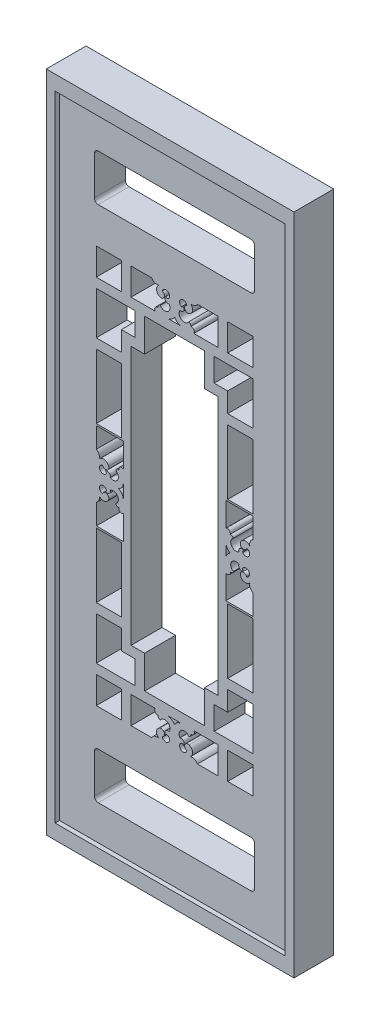
from build123d import *

# Parameters (mm, degrees)
SKETCH1_W            = 595
SKETCH1_H            = 1640
BOSS_EXTRUDE1_DEPTH  = 180
SKETCH_6_W           = 595
SKETCH_6_H           = 1640
CUT_EXTRUDE_2_DEPTH  = 100
CUT_EXTRUDE_3_DEPTH  = 100
SKETCH2_W            = 65
SKETCH2_H            = 70
SKETCH2_H_2          = 167
CUT_EXTRUDE_5_DEPTH  = 1747.432077122
CUT_EXTRUDE_8_DEPTH  = 1747.432077122
SCALE_1_SCALE        = 0.87394958
EXTRUDE_1_DEPTH      = 10
EXTRUDE_1_DEPTH_BACK = 79.92
SKETCH_8_W           = 560
SKETCH_8_H           = 1500
SKETCH_8_W_2         = 520
SKETCH_8_H_2         = 1433.277310924


with BuildPart() as part:
    # Sketch1 → Boss-Extrude1 (new body)
    with BuildSketch(Plane.XY):
        with Locations((297.5, 820)):
            Rectangle(SKETCH1_W, SKETCH1_H)
    extrude(amount=BOSS_EXTRUDE1_DEPTH)

    # 草图6 → 切除-拉伸2 (cut)
    with BuildSketch(Plane.XY.offset(180)):
        with Locations((297.5, 820)):
            Rectangle(SKETCH_6_W, SKETCH_6_H)
    extrude(amount=-CUT_EXTRUDE_2_DEPTH, mode=Mode.SUBTRACT)

    # 草图1 → 切除-拉伸3 (cut)
    with BuildSketch(Plane(origin=(0, 0, 0), x_dir=(-1, 0, 0), z_dir=(0, 0, -1))):
        with BuildLine():
            ThreePointArc((-339.478697135, 363.442307012), (-347.464207716, 366.462464977), (-347.449072001, 375))
            Line((-347.449072001, 375), (-410, 375))
            Line((-410, 375), (-410, 305))
            Line((-410, 305), (-356.673331708, 305))
            ThreePointArc((-356.673331708, 305), (-348.94904931, 312.012889726), (-338.529552639, 312.541330816))
            ThreePointArc((-338.529552639, 312.541330816), (-344.046220029, 325.924483031), (-334.768909443, 337.036363636))
            ThreePointArc((-334.768909443, 337.036363636), (-323.949287324, 331.726907665), (-329.315168468, 320.935157804))
            ThreePointArc((-329.315168468, 320.935157804), (-314.478603669, 315.069270244), (-315.214046212, 331.006378394))
            ThreePointArc((-315.214046212, 331.006378394), (-318.365986632, 330.765395418), (-320.358708006, 328.311447022))
            ThreePointArc((-320.358708006, 328.311447022), (-320.882047686, 338.069212343), (-311.577227356, 341.053870966))
            ThreePointArc((-311.577227356, 341.053870966), (-311.192434776, 341.798442865), (-310.72696898, 342.495432272))
            ThreePointArc((-310.72696898, 342.495432272), (-316.343126273, 360.498534643), (-334.477239272, 355.321000146))
            ThreePointArc((-334.477239272, 355.321000146), (-338.751843962, 358.289222889), (-339.478697135, 363.442307012))
        make_face()
        with BuildLine():
            Line((-279.5, 375), (-315.5, 375))
            ThreePointArc((-315.5, 375), (-304.873925683, 371.412833197), (-297.5, 362.9626))
            ThreePointArc((-297.5, 362.9626), (-290.126074317, 371.412833197), (-279.5, 375))
        make_face()
        with BuildLine():
            Line((-185, 375), (-247.550927999, 375))
            ThreePointArc((-247.550927999, 375), (-247.535792284, 366.462464977), (-255.521302865, 363.442307012))
            ThreePointArc((-255.521302865, 363.442307012), (-256.248156038, 358.289222889), (-260.522760728, 355.321000146))
            ThreePointArc((-260.522760728, 355.321000146), (-278.656873727, 360.498534643), (-284.27303102, 342.495432272))
            ThreePointArc((-284.27303102, 342.495432272), (-283.807565224, 341.798442865), (-283.422772644, 341.053870966))
            ThreePointArc((-283.422772644, 341.053870966), (-274.117952314, 338.069212343), (-274.641291994, 328.311447022))
            ThreePointArc((-274.641291994, 328.311447022), (-276.634013368, 330.765395418), (-279.785953788, 331.006378394))
            ThreePointArc((-279.785953788, 331.006378394), (-280.521396331, 315.069270244), (-265.684831532, 320.935157804))
            ThreePointArc((-265.684831532, 320.935157804), (-271.050712676, 331.726907665), (-260.231090557, 337.036363636))
            ThreePointArc((-260.231090557, 337.036363636), (-250.953779971, 325.924483031), (-256.470447361, 312.541330816))
            ThreePointArc((-256.470447361, 312.541330816), (-246.05095069, 312.012889726), (-238.326668292, 305))
            Line((-238.326668292, 305), (-185, 305))
            Line((-185, 305), (-185, 375))
        make_face()
    cut_extrude_3 = extrude(amount=-CUT_EXTRUDE_3_DEPTH, mode=Mode.SUBTRACT)

    # Sketch2 → 切除-拉伸5 (cut, through all)
    with BuildSketch(Plane(origin=(0, 0, 0), x_dir=(-1, 0, 0), z_dir=(0, 0, -1))):
        with Locations((-467.5, 1300)):
            Rectangle(SKETCH2_W, SKETCH2_H)
        Polygon((-400, 1240), (-500, 1240), (-500, 1129), (-435, 1129), (-435, 1180), (-400, 1180), align=None)
        with Locations((-467.5, 1020.5)):
            Rectangle(SKETCH2_W, SKETCH2_H_2)
        Polygon((-220, 1240), (-375, 1240), (-375, 1155), (-410, 1155), (-410, 485), (-375, 485), (-375, 400), (-220, 400), (-220, 485), (-185, 485), (-185, 1155), (-220, 1155), align=None)
        with Locations((-127.5, 1300)):
            Rectangle(SKETCH2_W, SKETCH2_H)
        Polygon((-95, 1240), (-195, 1240), (-195, 1180), (-160, 1180), (-160, 1129), (-95, 1129), align=None)
        with Locations((-467.5, 619.5)):
            Rectangle(SKETCH2_W, SKETCH2_H_2)
        with Locations((-127.5, 1020.5)):
            Rectangle(SKETCH2_W, SKETCH2_H_2)
        Polygon((-435, 511), (-500, 511), (-500, 400), (-400, 400), (-400, 460), (-435, 460), align=None)
        Polygon((-195, 460), (-195, 400), (-95, 400), (-95, 511), (-160, 511), (-160, 460), align=None)
        with Locations((-467.5, 340)):
            Rectangle(SKETCH2_W, SKETCH2_H)
        with Locations((-127.5, 619.5)):
            Rectangle(SKETCH2_W, SKETCH2_H_2)
        with Locations((-127.5, 340)):
            Rectangle(SKETCH2_W, SKETCH2_H)
        with BuildLine():
            Line((-100, 210), (-495, 210))
            ThreePointArc((-495, 210), (-502.071067812, 207.071067812), (-505, 200))
            Line((-505, 200), (-505, 100))
            ThreePointArc((-505, 100), (-502.071067812, 92.928932188), (-495, 90))
            Line((-495, 90), (-100, 90))
            ThreePointArc((-100, 90), (-92.928932188, 92.928932188), (-90, 100))
            Line((-90, 100), (-90, 200))
            ThreePointArc((-90, 200), (-92.928932188, 207.071067812), (-100, 210))
        make_face()
        with BuildLine():
            Line((-100, 1550), (-495, 1550))
            ThreePointArc((-495, 1550), (-502.071067812, 1547.071067812), (-505, 1540))
            Line((-505, 1540), (-505, 1440))
            ThreePointArc((-505, 1440), (-502.071067812, 1432.928932188), (-495, 1430))
            Line((-495, 1430), (-100, 1430))
            ThreePointArc((-100, 1430), (-92.928932188, 1432.928932188), (-90, 1440))
            Line((-90, 1440), (-90, 1540))
            ThreePointArc((-90, 1540), (-92.928932188, 1547.071067812), (-100, 1550))
        make_face()
    extrude(amount=-CUT_EXTRUDE_5_DEPTH, mode=Mode.SUBTRACT)

    # 镜向1: 切除-拉伸3 across plane
    add(cut_extrude_3.mirror(Plane.ZX.offset(820)), mode=Mode.SUBTRACT)

    # 草图1<5> → 切除-拉伸8 (cut, through all)
    with BuildSketch(Plane(origin=(0, 0, 0), x_dir=(-1, 0, 0), z_dir=(0, 0, -1))):
        with BuildLine():
            Line((-500, 760.826668292), (-500, 707.5))
            Line((-500, 707.5), (-430, 707.5))
            Line((-430, 707.5), (-430, 770.050927999))
            ThreePointArc((-430, 770.050927999), (-438.537535023, 770.035792284), (-441.557692988, 778.021302865))
            ThreePointArc((-441.557692988, 778.021302865), (-446.710777111, 778.748156038), (-449.678999854, 783.022760728))
            ThreePointArc((-449.678999854, 783.022760728), (-444.501465357, 801.156873727), (-462.504567728, 806.77303102))
            ThreePointArc((-462.504567728, 806.77303102), (-463.201557135, 806.307565224), (-463.946129034, 805.922772644))
            ThreePointArc((-463.946129034, 805.922772644), (-466.930787657, 796.617952314), (-476.688552978, 797.141291994))
            ThreePointArc((-476.688552978, 797.141291994), (-474.234604582, 799.134013368), (-473.993621606, 802.285953788))
            ThreePointArc((-473.993621606, 802.285953788), (-489.930729756, 803.021396331), (-484.064842196, 788.184831532))
            ThreePointArc((-484.064842196, 788.184831532), (-473.273092335, 793.550712676), (-467.963636364, 782.731090557))
            ThreePointArc((-467.963636364, 782.731090557), (-479.075516969, 773.453779971), (-492.458669184, 778.970447361))
            ThreePointArc((-492.458669184, 778.970447361), (-492.987110274, 768.55095069), (-500, 760.826668292))
        make_face()
        with BuildLine():
            ThreePointArc((-442.0374, 820), (-433.587166803, 812.626074317), (-430, 802))
            Line((-430, 802), (-430, 838))
            ThreePointArc((-430, 838), (-433.587166803, 827.373925683), (-442.0374, 820))
        make_face()
        with BuildLine():
            Line((-430, 869.949072001), (-430, 932.5))
            Line((-430, 932.5), (-500, 932.5))
            Line((-500, 932.5), (-500, 879.173331708))
            ThreePointArc((-500, 879.173331708), (-492.987110274, 871.44904931), (-492.458669184, 861.029552639))
            ThreePointArc((-492.458669184, 861.029552639), (-479.075516969, 866.546220029), (-467.963636364, 857.268909443))
            ThreePointArc((-467.963636364, 857.268909443), (-473.273092335, 846.449287324), (-484.064842196, 851.815168468))
            ThreePointArc((-484.064842196, 851.815168468), (-489.930729756, 836.978603669), (-473.993621606, 837.714046212))
            ThreePointArc((-473.993621606, 837.714046212), (-474.234604582, 840.865986631), (-476.688552978, 842.858708006))
            ThreePointArc((-476.688552978, 842.858708006), (-466.930787657, 843.382047686), (-463.946129034, 834.077227356))
            ThreePointArc((-463.946129034, 834.077227356), (-463.201557135, 833.692434776), (-462.504567728, 833.22696898))
            ThreePointArc((-462.504567728, 833.22696898), (-444.501465357, 838.843126273), (-449.678999854, 856.977239272))
            ThreePointArc((-449.678999854, 856.977239272), (-446.710777111, 861.251843962), (-441.557692988, 861.978697135))
            ThreePointArc((-441.557692988, 861.978697135), (-438.537535023, 869.964207716), (-430, 869.949072001))
        make_face()
    cut_extrude_8 = extrude(amount=-CUT_EXTRUDE_8_DEPTH, mode=Mode.SUBTRACT)

    # 镜向3: 切除-拉伸8 across plane
    add(cut_extrude_8.mirror(Plane.ZY.offset(-297.5)), mode=Mode.SUBTRACT)


with BuildPart() as part_1:
    # 缩放比例1: scaled about (297.5, 820, 40)
    add(part.part.scale(SCALE_1_SCALE).moved(Location((37.5, 103.361344538, 5.042016807))))

    # 草图8 → 凸台-拉伸1 (add, two sides: drawn at the far end of the back side and taken through both)
    with BuildSketch(Plane.XY.offset(74.957983193).offset(-EXTRUDE_1_DEPTH_BACK)):
        with Locations((297.5, 820.001344538)):
            Rectangle(SKETCH_8_W, SKETCH_8_H)
        with Locations((297.5, 820)):
            Rectangle(SKETCH_8_W_2, SKETCH_8_H_2, mode=Mode.SUBTRACT)
    extrude(amount=EXTRUDE_1_DEPTH + EXTRUDE_1_DEPTH_BACK)


solid = part_1.part
